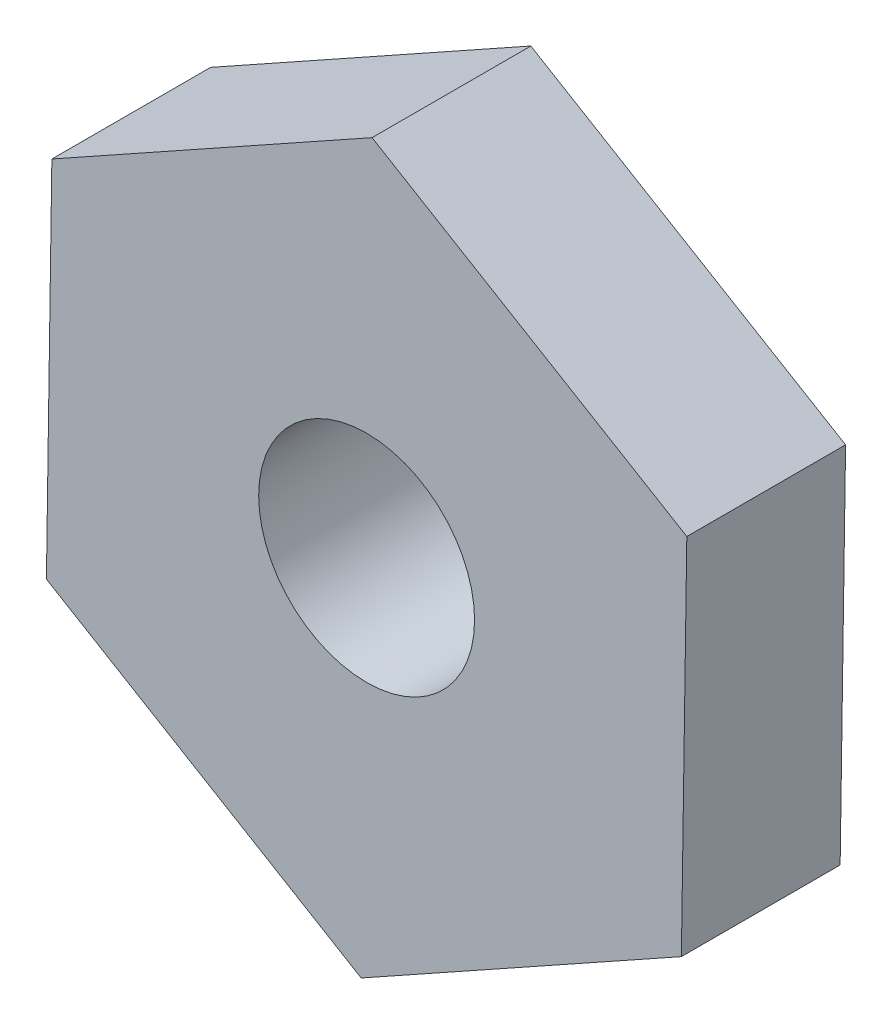
from build123d import *

# Parameters (mm, degrees)
BOSS_EXTRUDE1_DEPTH   = 5
M8_TAPPED_HOLE1_D     = 6.8
M8_TAPPED_HOLE1_DEPTH = 19.75
M8_TAPPED_HOLE1_TIP   = 2.042926105


with BuildPart() as part:
    # Sketch1 → Boss-Extrude1 (new body)
    with BuildSketch(Plane.XY):
        Polygon((9.913260994, -5.921198341), (10.084538681, 5.624536685), (0.171277687, 11.545735026), (-9.913260994, 5.921198341), (-10.084538681, -5.624536685), (-0.171277687, -11.545735026), align=None)
    extrude(amount=BOSS_EXTRUDE1_DEPTH)

    # M8 Tapped Hole1
    with Locations(Plane.XY.offset(5)):
        with Locations((0, 0)):
            Hole(M8_TAPPED_HOLE1_D / 2, depth=M8_TAPPED_HOLE1_DEPTH)
            with Locations((0, 0, -(M8_TAPPED_HOLE1_DEPTH + M8_TAPPED_HOLE1_TIP / 2))):  # 118° drill point
                Cone(0, M8_TAPPED_HOLE1_D / 2, M8_TAPPED_HOLE1_TIP, mode=Mode.SUBTRACT)


solid = part.part
